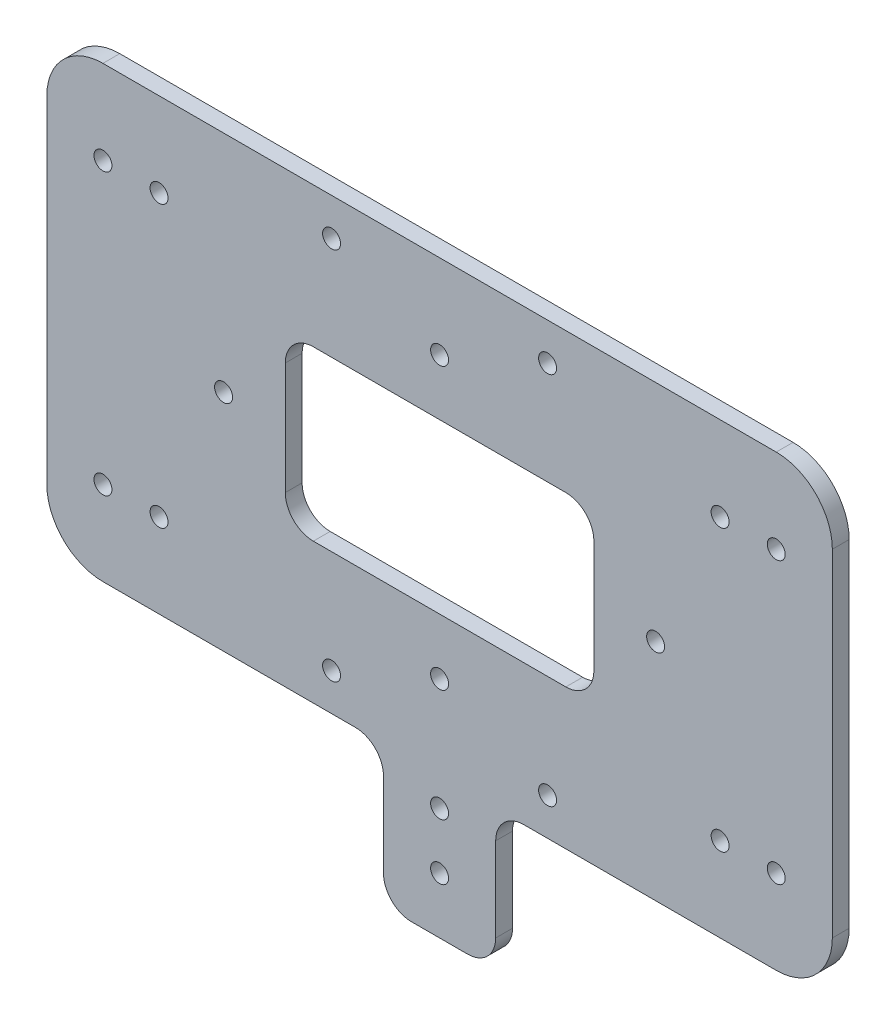
from build123d import *

# Parameters (mm, degrees)
SKETCH_1_W          = 140
SKETCH_1_H          = 80
SKETCH_1_R          = 1.6
EXTRUDE_1_DEPTH     = 3
SKETCH_2_R          = 1.6
CUT_EXTRUDE_1_DEPTH = 10
SKETCH_3_W          = 55
SKETCH_3_H          = 30
CUT_EXTRUDE_2_DEPTH = 10
FILLET_1_R          = 5
FILLET_2_R          = 10
SKETCH_4_R          = 1.6
CUT_EXTRUDE_3_DEPTH = 10
SKETCH_6_W          = 20
SKETCH_6_H          = 25
EXTRUDE_2_DEPTH     = 3
SKETCH_7_R          = 1.6
CUT_EXTRUDE_5_DEPTH = 4
FILLET_3_R          = 5


with BuildPart() as part:
    # 草图1 → 凸台-拉伸1 (new body)
    with BuildSketch(Plane.XY):
        Rectangle(SKETCH_1_W, SKETCH_1_H)
        with Locations((19.25, 33.341978046)):
            Circle(SKETCH_1_R, mode=Mode.SUBTRACT)
        with Locations((38.5, 0)):
            Circle(SKETCH_1_R, mode=Mode.SUBTRACT)
        with Locations((19.25, -33.341978046)):
            Circle(SKETCH_1_R, mode=Mode.SUBTRACT)
        with Locations((-19.25, -33.341978046)):
            Circle(SKETCH_1_R, mode=Mode.SUBTRACT)
        with Locations((-38.5, 0)):
            Circle(SKETCH_1_R, mode=Mode.SUBTRACT)
        with Locations((-19.25, 33.341978046)):
            Circle(SKETCH_1_R, mode=Mode.SUBTRACT)
    extrude(amount=EXTRUDE_1_DEPTH)

    # 草图2 → 切除-拉伸1 (cut)
    with BuildSketch(Plane.XY.offset(3)):
        with Locations((0, 25)):
            Circle(SKETCH_2_R)
        with Locations((-60, 25)):
            Circle(SKETCH_2_R)
        with Locations((60, 25)):
            Circle(SKETCH_2_R)
        with Locations((60, -25)):
            Circle(SKETCH_2_R)
        with Locations((-60, -25)):
            Circle(SKETCH_2_R)
        with Locations((0, -25)):
            Circle(SKETCH_2_R)
    extrude(amount=-CUT_EXTRUDE_1_DEPTH, mode=Mode.SUBTRACT)

    # 草图3 → 切除-拉伸2 (cut)
    with BuildSketch(Plane.XY.offset(3)):
        Rectangle(SKETCH_3_W, SKETCH_3_H)
    extrude(amount=-CUT_EXTRUDE_2_DEPTH, mode=Mode.SUBTRACT)

    # 圆角1
    fillet_1_edges = [part.edges().sort_by_distance(p)[0] for p in [
        (27.5, 15, 1.5),
        (27.5, -15, 1.5),
        (-27.5, -15, 1.5),
        (-27.5, 15, 1.5),
    ]]
    fillet(fillet_1_edges, radius=FILLET_1_R)

    # 圆角2
    fillet_2_edges = [part.edges().sort_by_distance(p)[0] for p in [
        (70, -40, 1.5),
        (-70, -40, 1.5),
        (-70, 40, 1.5),
        (70, 40, 1.5),
    ]]
    fillet(fillet_2_edges, radius=FILLET_2_R)

    # 草图4 → 切除-拉伸3 (cut)
    with BuildSketch(Plane.XY.offset(3)):
        with Locations((-50, 25)):
            Circle(SKETCH_4_R)
        with Locations((-50, -25)):
            Circle(SKETCH_4_R)
        with Locations((50, -25)):
            Circle(SKETCH_4_R)
        with Locations((50, 25)):
            Circle(SKETCH_4_R)
    extrude(amount=-CUT_EXTRUDE_3_DEPTH, mode=Mode.SUBTRACT)

    # 草图6 → 凸台-拉伸2 (add)
    with BuildSketch(Plane.XY.offset(3)):
        with Locations((0, -52.5)):
            Rectangle(SKETCH_6_W, SKETCH_6_H)
    extrude(amount=-EXTRUDE_2_DEPTH)

    # 草图7 → 切除-拉伸5 (cut, through all)
    with BuildSketch(Plane.XY.offset(3)):
        with Locations((0, -45)):
            Circle(SKETCH_7_R)
        with Locations((0, -55)):
            Circle(SKETCH_7_R)
    extrude(amount=-CUT_EXTRUDE_5_DEPTH, mode=Mode.SUBTRACT)

    # 圆角3
    fillet_3_edges = [part.edges().sort_by_distance(p)[0] for p in [
        (-10, -40, 1.5),
        (10, -40, 1.5),
        (10, -65, 1.5),
        (-10, -65, 1.5),
    ]]
    fillet(fillet_3_edges, radius=FILLET_3_R)


solid = part.part
